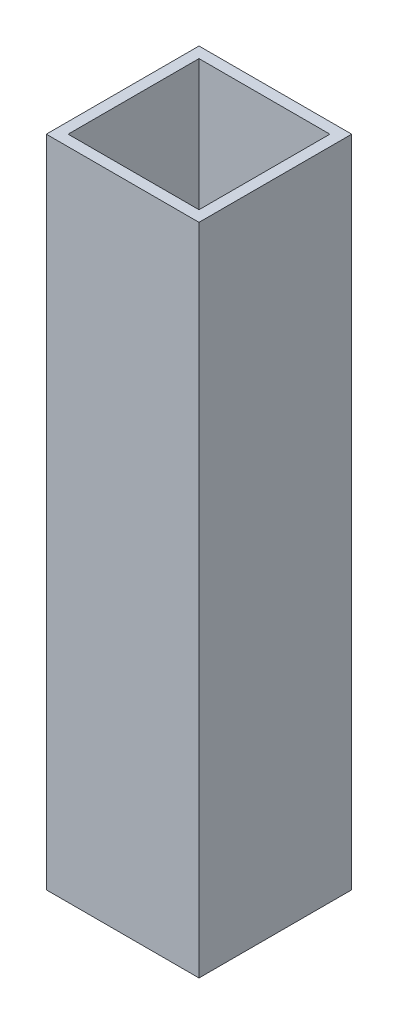
from build123d import *

# Parameters (mm, degrees)
BOSS_EXTRUDE1_DEPTH      = 95.25
BOSS_EXTRUDE1_DEPTH_BACK = 95.25
SKETCH1_W                = 44.45
SKETCH1_H                = 44.45
SKETCH1_W_2              = 38.1
SKETCH1_H_2              = 38.1


with BuildPart() as part:
    # Sketch1 → Boss-Extrude1 (new, two sides: drawn at the far end of the back side and taken through both)
    with BuildSketch(Plane(origin=(0, 0, 0), x_dir=(1, 0, 0), z_dir=(0, 1, 0)).offset(-BOSS_EXTRUDE1_DEPTH_BACK)):
        Rectangle(SKETCH1_W, SKETCH1_H)
        Rectangle(SKETCH1_W_2, SKETCH1_H_2, mode=Mode.SUBTRACT)
    extrude(amount=BOSS_EXTRUDE1_DEPTH + BOSS_EXTRUDE1_DEPTH_BACK)


solid = part.part
